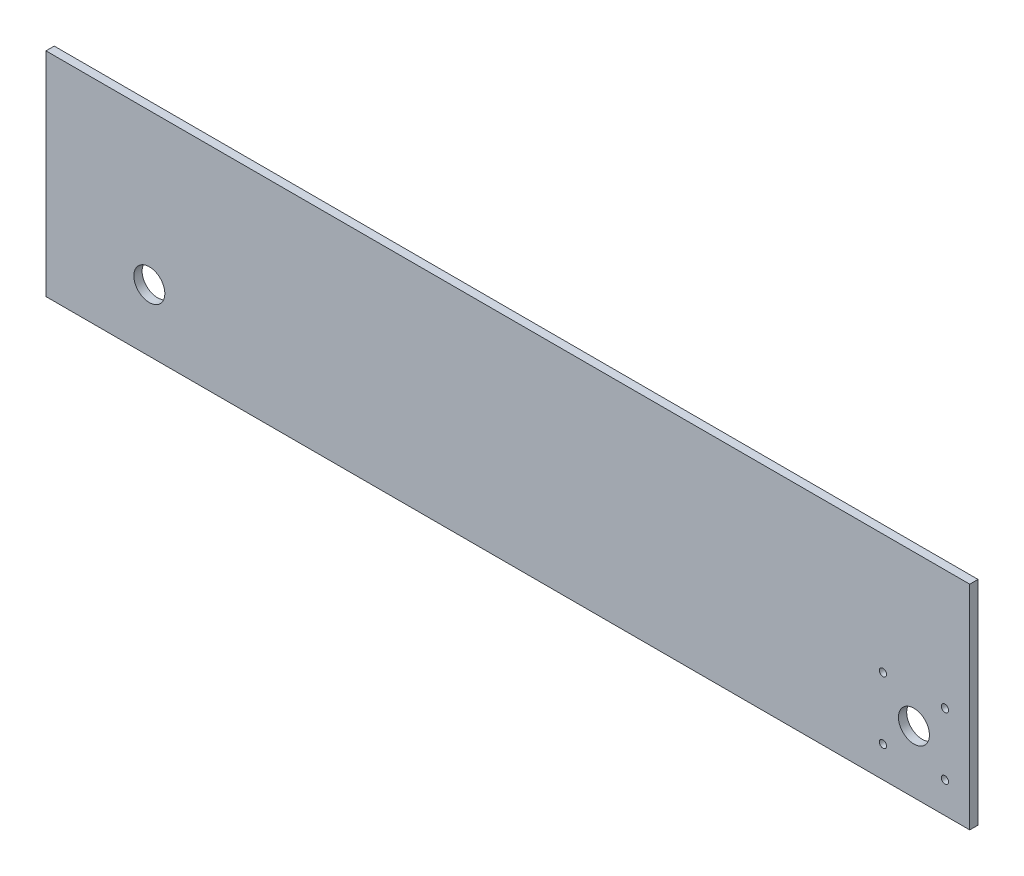
from build123d import *

# Parameters (mm, degrees)
SKETCH1_W           = 450
SKETCH1_H           = 103
BOSS_EXTRUDE1_DEPTH = 4
SKETCH6_R           = 7.5
CUT_EXTRUDE4_DEPTH  = 5
SKETCH7_R           = 7.5
CUT_EXTRUDE5_DEPTH  = 5
SKETCH8_R           = 1.75
CUT_EXTRUDE6_DEPTH  = 5
SKETCH10_W          = 3
SKETCH10_H          = 103
CUT_EXTRUDE7_DEPTH  = 10


with BuildPart() as part:
    # Sketch1 → Boss-Extrude1 (new body)
    with BuildSketch(Plane.XY):
        with Locations((225, 51.5)):
            Rectangle(SKETCH1_W, SKETCH1_H)
    extrude(amount=BOSS_EXTRUDE1_DEPTH)

    # Sketch6 → Cut-Extrude4 (cut, through all)
    with BuildSketch(Plane.XY.offset(4)):
        with Locations((50, 30)):
            Circle(SKETCH6_R)
    extrude(amount=-CUT_EXTRUDE4_DEPTH, mode=Mode.SUBTRACT)

    # Sketch7 → Cut-Extrude5 (cut, through all)
    with BuildSketch(Plane.XY.offset(4)):
        with Locations((420, 30)):
            Circle(SKETCH7_R)
    extrude(amount=-CUT_EXTRUDE5_DEPTH, mode=Mode.SUBTRACT)

    # Sketch8 → Cut-Extrude6 (cut, through all)
    with BuildSketch(Plane.XY.offset(4)):
        with Locations((435, 45)):
            Circle(SKETCH8_R)
        with Locations((405, 45)):
            Circle(SKETCH8_R)
        with Locations((405, 15)):
            Circle(SKETCH8_R)
        with Locations((435, 15)):
            Circle(SKETCH8_R)
    extrude(amount=-CUT_EXTRUDE6_DEPTH, mode=Mode.SUBTRACT)

    # Sketch10 → Cut-Extrude7 (cut)
    with BuildSketch(Plane(origin=(0, 0, 0), x_dir=(-1, 0, 0), z_dir=(0, 0, -1))):
        with Locations((-448.5, 51.5)):
            Rectangle(SKETCH10_W, SKETCH10_H)
    extrude(amount=-CUT_EXTRUDE7_DEPTH, mode=Mode.SUBTRACT)


solid = part.part
